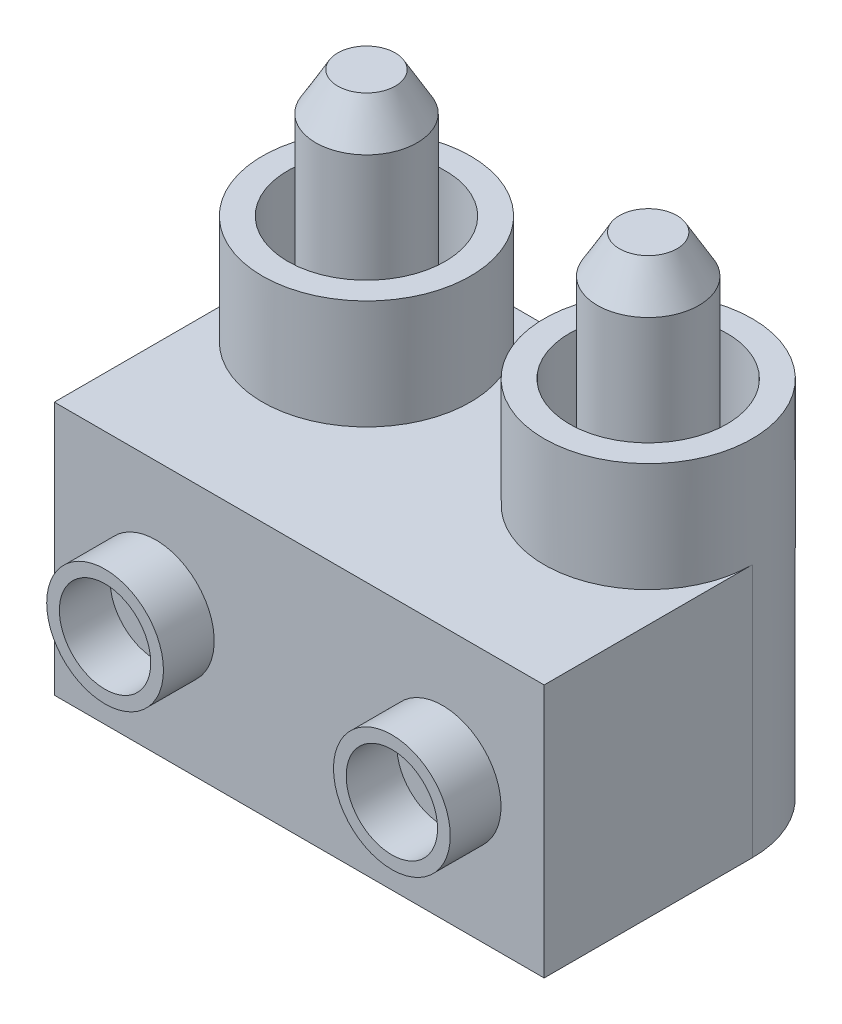
from build123d import *

# Parameters (mm, degrees)
BOSS_EXTRUDE1_DEPTH   = 10
SKETCH3_R             = 4.1
SKETCH3_R_2           = 3.1
BOSS_EXTRUDE2_DEPTH   = 4.3
SKETCH4_R             = 2
BOSS_EXTRUDE3_DEPTH   = 9.3
BOSS_EXTRUDE3_2_DEPTH = 9.3
CHAMFER1_SIZE         = 1.5
CHAMFER1_SIZE2        = 0.866025404
CHAMFER2_SIZE         = 1.5
CHAMFER2_SIZE2        = 0.866025404
SKETCH5_R             = 2.3
SKETCH5_R_2           = 1.8
BOSS_EXTRUDE4_DEPTH   = 2


with BuildPart() as part:
    # Sketch2 → Boss-Extrude1 (new body)
    with BuildSketch(Plane(origin=(0, 0, 0), x_dir=(1, 0, 0), z_dir=(0, 1, 0))):
        with BuildLine():
            Line((-5.55, 6.15), (5.55, 6.15))
            ThreePointArc((5.55, 6.15), (8.449137803, 4.949137803), (9.65, 2.05))
            Line((9.65, 2.05), (9.65, -6.15))
            Line((9.65, -6.15), (-9.65, -6.15))
            Line((-9.65, -6.15), (-9.65, 2.05))
            ThreePointArc((-9.65, 2.05), (-8.449137803, 4.949137803), (-5.55, 6.15))
        make_face()
    extrude(amount=BOSS_EXTRUDE1_DEPTH)

    # Sketch3 → Boss-Extrude2 (add)
    with BuildSketch(Plane(origin=(0, 10, 0), x_dir=(1, 0, 0), z_dir=(0, 1, 0))):
        with Locations((-5.55, 2.05)):
            Circle(SKETCH3_R)
        with Locations((-5.55, 2.05)):
            Circle(SKETCH3_R_2, mode=Mode.SUBTRACT)
        with Locations((5.55, 2.05)):
            Circle(SKETCH3_R)
        with Locations((5.55, 2.05)):
            Circle(SKETCH3_R_2, mode=Mode.SUBTRACT)
    extrude(amount=BOSS_EXTRUDE2_DEPTH)

    # Sketch5 → Boss-Extrude4 (add)
    with BuildSketch(Plane.XY.offset(6.15)):
        with Locations((-5.65, 5)):
            Circle(SKETCH5_R)
        with Locations((-5.65, 5)):
            Circle(SKETCH5_R_2, mode=Mode.SUBTRACT)
        with Locations((5.65, 5)):
            Circle(SKETCH5_R)
        with Locations((5.65, 5)):
            Circle(SKETCH5_R_2, mode=Mode.SUBTRACT)
    extrude(amount=BOSS_EXTRUDE4_DEPTH)


with BuildPart() as body_2:
    # Sketch4 → Boss-Extrude3 (new body)
    with BuildSketch(Plane(origin=(0, 10, 0), x_dir=(1, 0, 0), z_dir=(0, 1, 0))):
        with Locations((-5.55, 2.05)):
            Circle(SKETCH4_R)
    extrude(amount=BOSS_EXTRUDE3_DEPTH)

    # Chamfer1
    chamfer1_edges = [body_2.edges().sort_by_distance(p)[0] for p in [
        (-7.55, 19.3, -2.05),
    ]]
    chamfer1_side = [body_2.faces().sort_by_distance(p)[0] for p in [
        (-7.55, 14.65, -2.05),
    ]]
    chamfer(chamfer1_edges, length=CHAMFER1_SIZE, length2=CHAMFER1_SIZE2, reference=chamfer1_side[0])


with BuildPart() as body_3:
    # Sketch4 → Boss-Extrude3 2 (new body)
    with BuildSketch(Plane(origin=(0, 10, 0), x_dir=(1, 0, 0), z_dir=(0, 1, 0))):
        with Locations((5.55, 2.05)):
            Circle(SKETCH4_R)
    extrude(amount=BOSS_EXTRUDE3_2_DEPTH)

    # Chamfer2
    chamfer2_edges = [body_3.edges().sort_by_distance(p)[0] for p in [
        (3.55, 19.3, -2.05),
    ]]
    chamfer2_side = [body_3.faces().sort_by_distance(p)[0] for p in [
        (3.55, 14.65, -2.05),
    ]]
    chamfer(chamfer2_edges, length=CHAMFER2_SIZE, length2=CHAMFER2_SIZE2, reference=chamfer2_side[0])


solid = Compound([part.part, body_2.part, body_3.part])
